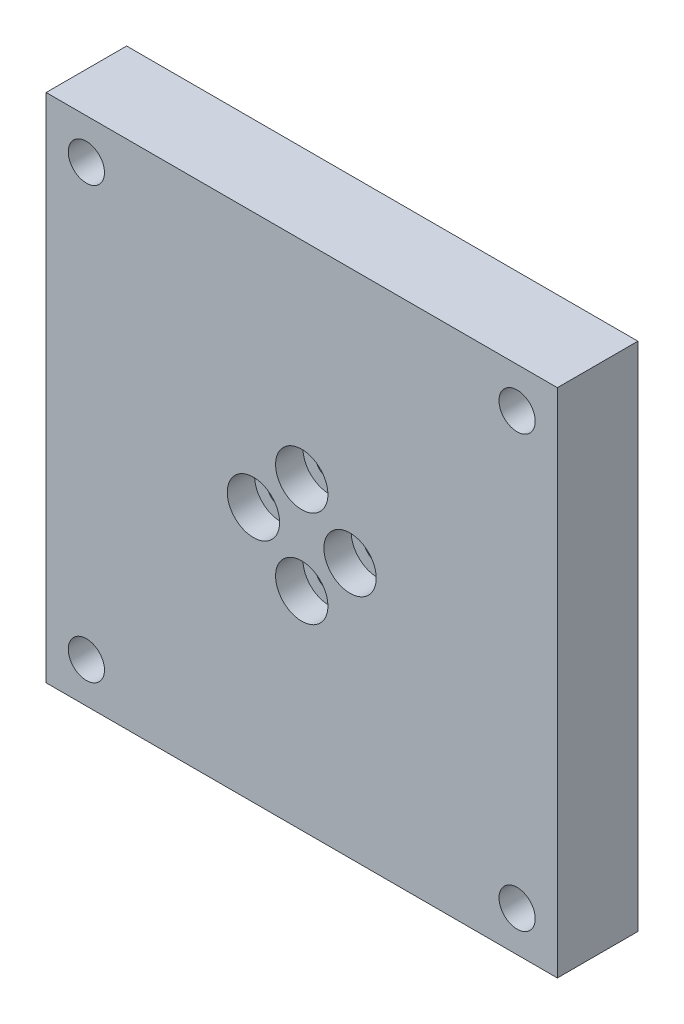
from build123d import *

# Parameters (mm, degrees)
SKETCH_1_W                  = 63.5
SKETCH_1_H                  = 63.5
EXTRUDE_1_DEPTH             = 10
HOLE_WIZARD_M31_D           = 3.4
HOLE_WIZARD_M31_CBORE_D     = 6.5
HOLE_WIZARD_M31_CBORE_DEPTH = 3.4
HOLE_WIZARD_M41_D           = 4.5
HOLE_WIZARD_M41_CBORE_D     = 8
HOLE_WIZARD_M41_CBORE_DEPTH = 4.4
SKETCH_8_R                  = 12.5
CUT_EXTRUDE_1_DEPTH         = 7
EXTRUDE_2_DEPTH             = 7
FILLET_1_R                  = 3


with BuildPart() as part:
    # Эскиз1 → Бобышка-Вытянуть1 (new body)
    with BuildSketch(Plane.XY):
        Rectangle(SKETCH_1_W, SKETCH_1_H)
    extrude(amount=EXTRUDE_1_DEPTH)

    # Цековка для винта с внутренним шестигранником M31 (through all)
    with Locations(Plane.XY.offset(10)):
        with Locations((0, 6), (-6, 0), (0, -6), (6, 0)):
            CounterBoreHole(HOLE_WIZARD_M31_D / 2, HOLE_WIZARD_M31_CBORE_D / 2, HOLE_WIZARD_M31_CBORE_DEPTH)

    # Цековка для винта с внутренним шестигранником M41 (through all)
    with Locations(Plane(origin=(0, 0, 0), x_dir=(-1, 0, 0), z_dir=(0, 0, -1))):
        with Locations((-26.75, 26.75), (-26.75, -26.75), (26.75, -26.75), (26.75, 26.75)):
            CounterBoreHole(HOLE_WIZARD_M41_D / 2, HOLE_WIZARD_M41_CBORE_D / 2, HOLE_WIZARD_M41_CBORE_DEPTH)

    # Эскиз8 → Вырез-Вытянуть1 (cut)
    with BuildSketch(Plane(origin=(0, 0, 0), x_dir=(-1, 0, 0), z_dir=(0, 0, -1))):
        with BuildLine():
            Line((-28.75, 16.800125629), (-28.75, -16.800125629))
            ThreePointArc((-28.75, -16.800125629), (-27.974859546, -18.812586809), (-26.05, -19.78508794))
            ThreePointArc((-26.05, -19.78508794), (-21.800252532, -21.800252532), (-19.78508794, -26.05))
            ThreePointArc((-19.78508794, -26.05), (-18.812586809, -27.974859546), (-16.800125629, -28.75))
            Line((-16.800125629, -28.75), (16.800125629, -28.75))
            ThreePointArc((16.800125629, -28.75), (18.812586809, -27.974859546), (19.78508794, -26.05))
            ThreePointArc((19.78508794, -26.05), (21.800252532, -21.800252532), (26.05, -19.78508794))
            ThreePointArc((26.05, -19.78508794), (27.974859546, -18.812586809), (28.75, -16.800125629))
            Line((28.75, -16.800125629), (28.75, 16.800125629))
            ThreePointArc((28.75, 16.800125629), (27.974859546, 18.812586809), (26.05, 19.78508794))
            ThreePointArc((26.05, 19.78508794), (21.800252532, 21.800252532), (19.78508794, 26.05))
            ThreePointArc((19.78508794, 26.05), (18.812586809, 27.974859546), (16.800125629, 28.75))
            Line((16.800125629, 28.75), (-16.800125629, 28.75))
            ThreePointArc((-16.800125629, 28.75), (-18.812586809, 27.974859546), (-19.78508794, 26.05))
            ThreePointArc((-19.78508794, 26.05), (-21.800252532, 21.800252532), (-26.05, 19.78508794))
            ThreePointArc((-26.05, 19.78508794), (-27.974859546, 18.812586809), (-28.75, 16.800125629))
        make_face()
        Circle(SKETCH_8_R, mode=Mode.SUBTRACT)
    extrude(amount=-CUT_EXTRUDE_1_DEPTH, mode=Mode.SUBTRACT)

    # Эскиз9 → Бобышка-Вытянуть2 (add)
    with BuildSketch(Plane(origin=(0, 0, 7), x_dir=(-1, 0, 0), z_dir=(0, 0, -1))):
        with BuildLine():
            Line((20.854569927, 22.97589027), (7.714304216, 9.835624559))
            ThreePointArc((7.714304216, 9.835624559), (8.838834765, 8.838834765), (9.835624559, 7.714304216))
            Line((9.835624559, 7.714304216), (22.97589027, 20.854569927))
            ThreePointArc((22.97589027, 20.854569927), (21.800252532, 21.800252532), (20.854569927, 22.97589027))
        make_face()
        with BuildLine():
            Line((-22.97589027, 20.854569927), (-9.835624559, 7.714304216))
            ThreePointArc((-9.835624559, 7.714304216), (-8.838834765, 8.838834765), (-7.714304216, 9.835624559))
            Line((-7.714304216, 9.835624559), (-20.854569927, 22.97589027))
            ThreePointArc((-20.854569927, 22.97589027), (-21.800252532, 21.800252532), (-22.97589027, 20.854569927))
        make_face()
        with BuildLine():
            Line((7.714304216, -9.835624559), (20.854569927, -22.97589027))
            ThreePointArc((20.854569927, -22.97589027), (21.800252532, -21.800252532), (22.97589027, -20.854569927))
            Line((22.97589027, -20.854569927), (9.835624559, -7.714304216))
            ThreePointArc((9.835624559, -7.714304216), (8.838834765, -8.838834765), (7.714304216, -9.835624559))
        make_face()
        with BuildLine():
            Line((-7.714304216, -9.835624559), (-20.854569927, -22.97589027))
            ThreePointArc((-20.854569927, -22.97589027), (-21.800252532, -21.800252532), (-22.97589027, -20.854569927))
            Line((-22.97589027, -20.854569927), (-9.835624559, -7.714304216))
            ThreePointArc((-9.835624559, -7.714304216), (-8.838834765, -8.838834765), (-7.714304216, -9.835624559))
        make_face()
    extrude(amount=EXTRUDE_2_DEPTH)

    # Скругление1
    fillet_1_edges = [part.edges().sort_by_distance(p)[0] for p in [
        (-20.854569927, 22.97589027, 3.5),
        (-22.97589027, 20.854569927, 3.5),
        (-9.835624559, 7.714304216, 3.5),
        (-7.714304216, 9.835624559, 3.5),
        (9.835624559, -7.714304216, 3.5),
        (7.714304216, -9.835624559, 3.5),
        (20.854569927, -22.97589027, 3.5),
        (22.97589027, -20.854569927, 3.5),
        (22.97589027, 20.854569927, 3.5),
        (20.854569927, 22.97589027, 3.5),
        (7.714304216, 9.835624559, 3.5),
        (9.835624559, 7.714304216, 3.5),
        (-7.714304216, -9.835624559, 3.5),
        (-9.835624559, -7.714304216, 3.5),
        (-22.97589027, -20.854569927, 3.5),
        (-20.854569927, -22.97589027, 3.5),
    ]]
    fillet(fillet_1_edges, radius=FILLET_1_R)


solid = part.part
